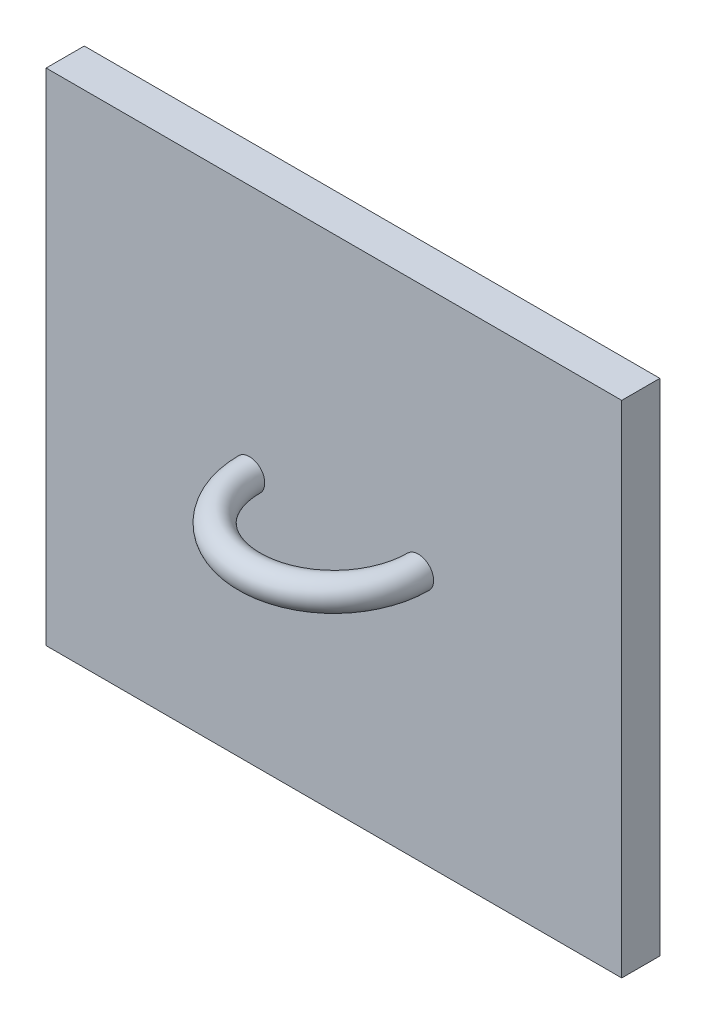
from build123d import *

# Parameters (mm, degrees)
SKETCH1_W           = 188.7
SKETCH1_H           = 164
BOSS_EXTRUDE1_DEPTH = 12.5
SKETCH3_R           = 5
REVOLVE1_ANGLE      = 180


with BuildPart() as part:
    # Sketch1 → Boss-Extrude1 (new body)
    with BuildSketch(Plane.XY):
        with Locations((94.35, 82)):
            Rectangle(SKETCH1_W, SKETCH1_H)
    extrude(amount=BOSS_EXTRUDE1_DEPTH)

    # Sketch3 → Revolve1 (revolve)
    with BuildSketch(Plane.XY.offset(12.5)):
        with Locations((66.676185661, 82)):
            Circle(SKETCH3_R)
    revolve(axis=Axis((94.35, 164, 12.5), (0, 1, 0)), revolution_arc=REVOLVE1_ANGLE)


solid = part.part
